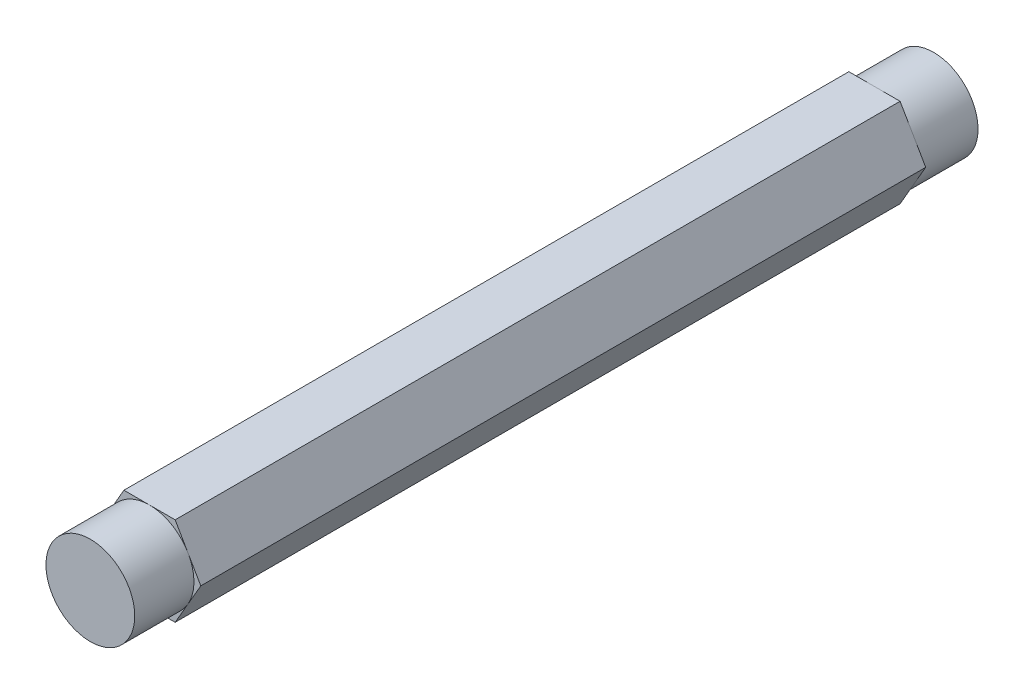
from build123d import *

# Parameters (mm, degrees)
BOSS_EXTRUDE1_DEPTH = 77.7875
SKETCH2_R           = 4.7625
BOSS_EXTRUDE2_DEPTH = 6.35
SKETCH3_R           = 4.7625
BOSS_EXTRUDE3_DEPTH = 6.35


with BuildPart() as part:
    # Sketch1 → Boss-Extrude1 (new body)
    with BuildSketch(Plane.XY):
        Polygon((-2.749630657, -4.7625), (2.749630657, -4.7625), (5.499261314, 0), (2.749630657, 4.7625), (-2.749630657, 4.7625), (-5.499261314, 0), align=None)
    extrude(amount=BOSS_EXTRUDE1_DEPTH)

    # Sketch2 → Boss-Extrude2 (add)
    with BuildSketch(Plane.XY.offset(77.7875)):
        with Locations(Location((0, 0, 0), (0, 0, 150))):  # turned: the seam where the file's is
            Circle(SKETCH2_R)
    extrude(amount=BOSS_EXTRUDE2_DEPTH)

    # Sketch3 → Boss-Extrude3 (add)
    with BuildSketch(Plane(origin=(0, 0, 0), x_dir=(-1, 0, 0), z_dir=(0, 0, -1))):
        with Locations(Location((0, 0, 0), (0, 0, 30))):  # turned: the seam where the file's is
            Circle(SKETCH3_R)
    extrude(amount=BOSS_EXTRUDE3_DEPTH)


solid = part.part
